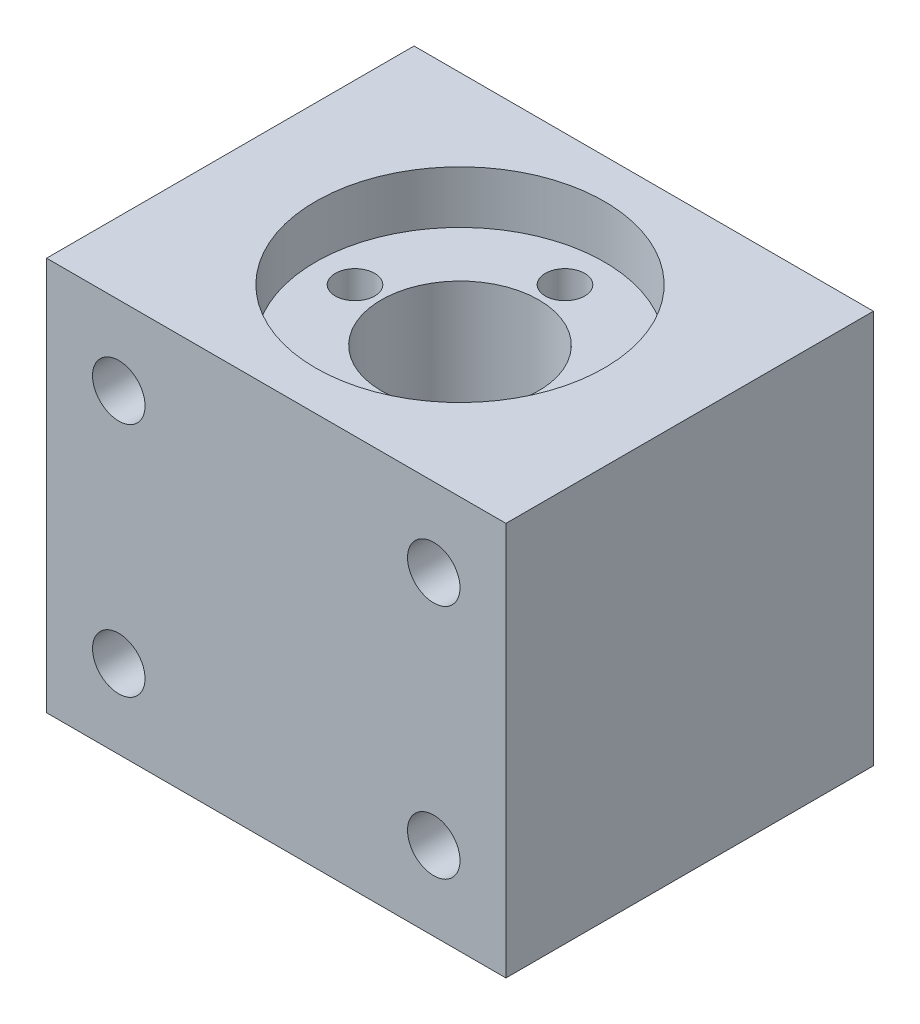
from build123d import *

# Parameters (mm, degrees)
SKETCH1_W           = 35
SKETCH1_H           = 30
BOSS_EXTRUDE1_DEPTH = 28
SKETCH2_R           = 2
CUT_EXTRUDE1_DEPTH  = 7
SKETCH4_R           = 7
CUT_EXTRUDE2_DEPTH  = 8
SKETCH5_R           = 6
CUT_EXTRUDE3_DEPTH  = 50
SKETCH6_R           = 11
CUT_EXTRUDE4_DEPTH  = 4
SKETCH7_R           = 1.5
CUT_EXTRUDE5_DEPTH  = 10
SKETCH8_R           = 1.5
CUT_EXTRUDE6_DEPTH  = 10


with BuildPart() as part:
    # Sketch1 → Boss-Extrude1 (new body)
    with BuildSketch(Plane.XY):
        with Locations((17.5, 15)):
            Rectangle(SKETCH1_W, SKETCH1_H)
    extrude(amount=BOSS_EXTRUDE1_DEPTH)

    # Sketch2 → Cut-Extrude1 (cut)
    with BuildSketch(Plane.XY.offset(28)):
        with Locations((5.5, 24)):
            Circle(SKETCH2_R)
        with Locations((5.5, 6)):
            Circle(SKETCH2_R)
        with Locations((29.5, 6)):
            Circle(SKETCH2_R)
        with Locations((29.5, 24)):
            Circle(SKETCH2_R)
    extrude(amount=-CUT_EXTRUDE1_DEPTH, mode=Mode.SUBTRACT)

    # Sketch4 → Cut-Extrude2 (cut)
    with BuildSketch(Plane.XZ):
        with Locations((17.5, 14)):
            Circle(SKETCH4_R)
    extrude(amount=-CUT_EXTRUDE2_DEPTH, mode=Mode.SUBTRACT)

    # Sketch5 → Cut-Extrude3 (cut)
    with BuildSketch(Plane(origin=(0, 8, 0), x_dir=(-1, 0, 0), z_dir=(0, -1, 0))):
        with Locations((-17.5, -14)):
            Circle(SKETCH5_R)
    extrude(amount=-CUT_EXTRUDE3_DEPTH, mode=Mode.SUBTRACT)

    # Sketch6 → Cut-Extrude4 (cut)
    with BuildSketch(Plane(origin=(0, 30, 0), x_dir=(1, 0, 0), z_dir=(0, 1, 0))):
        with Locations((17.5, -14)):
            Circle(SKETCH6_R)
    extrude(amount=-CUT_EXTRUDE4_DEPTH, mode=Mode.SUBTRACT)

    # Sketch7 → Cut-Extrude5 (cut)
    with BuildSketch(Plane(origin=(0, 26, 0), x_dir=(1, 0, 0), z_dir=(0, 1, 0))):
        with Locations((17.5, -6)):
            Circle(SKETCH7_R)
        with Locations((9.5, -14)):
            Circle(SKETCH7_R)
        with Locations((17.5, -22)):
            Circle(SKETCH7_R)
        with Locations((25.5, -14)):
            Circle(SKETCH7_R)
    extrude(amount=-CUT_EXTRUDE5_DEPTH, mode=Mode.SUBTRACT)

    # Sketch8 → Cut-Extrude6 (cut)
    with BuildSketch(Plane(origin=(0, 0, 0), x_dir=(-1, 0, 0), z_dir=(0, 0, -1))):
        with Locations((-5, 15)):
            Circle(SKETCH8_R)
    extrude(amount=-CUT_EXTRUDE6_DEPTH, mode=Mode.SUBTRACT)


solid = part.part
